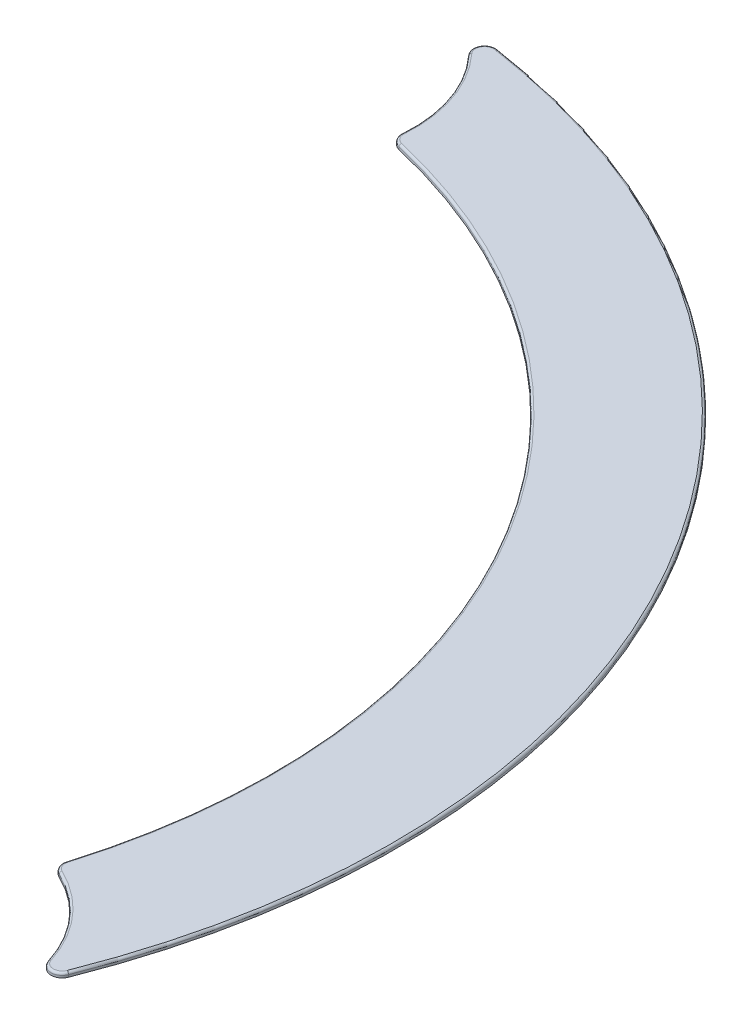
from build123d import *

# Parameters (mm, degrees)
BOSS_EXTRUDE1_DEPTH = 0.2
FILLET1_R           = 0.5
FILLET2_R           = 0.1


with BuildPart() as part:
    # Sketch1 → Boss-Extrude1 (new body)
    with BuildSketch(Plane(origin=(0, 0, 0), x_dir=(1, 0, 0), z_dir=(0, 1, 0))):
        with BuildLine():
            ThreePointArc((5.933363116, 27.108258929), (5.445514195, 30.519201292), (3.161776385, 33.099330357))
            ThreePointArc((3.161776385, 33.099330357), (28.795344676, 16.625), (30.24574913, -13.811486508))
            ThreePointArc((30.24574913, -13.811486508), (29.15316072, -10.543647016), (26.443122442, -8.415686276))
            ThreePointArc((26.443122442, -8.415686276), (24.032204955, 13.875), (5.933363116, 27.108258929))
        make_face()
    extrude(amount=BOSS_EXTRUDE1_DEPTH)

    # Fillet1
    fillet1_edges = [part.edges().sort_by_distance(p)[0] for p in [
        (5.933363116, 0.1, -27.108258929),
        (3.161776385, 0.1, -33.099330357),
        (30.24574913, 0.1, 13.811486508),
        (26.443122442, 0.1, 8.415686276),
    ]]
    fillet(fillet1_edges, radius=FILLET1_R)

    # Fillet2
    fillet2_edges = [part.edges().sort_by_distance(p)[0] for p in [
        (5.67065858, 0.2, -29.960518111),
        (28.795344676, 0.2, -16.625),
        (24.032204955, 0.2, -13.875),
        (28.781899085, 0.2, 10.069324669),
        (30.432518733, 0.2, 12.554273543),
        (26.595741318, 0.2, 8.338247788),
        (6.076736251, 0.2, -27.201711507),
        (4.343939552, 0.2, -32.632471095),
    ]]
    fillet(fillet2_edges, radius=FILLET2_R)


solid = part.part
